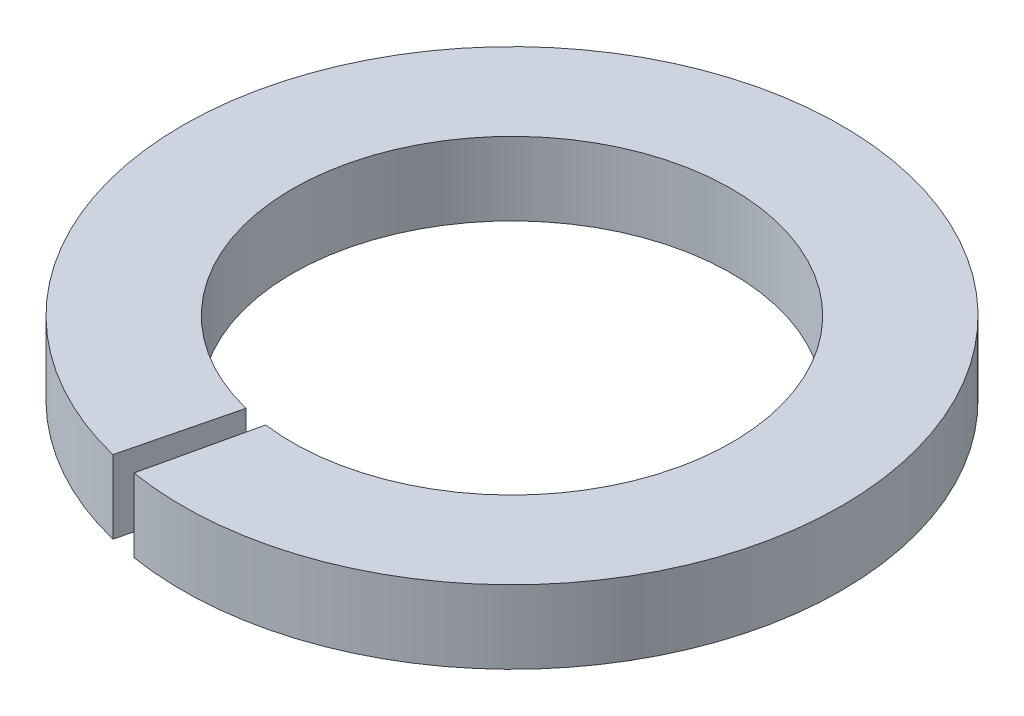
from build123d import *

# Parameters (mm, degrees)
EXTRUDE_1_DEPTH = 1


with BuildPart() as part:
    # Эскиз1 → Бобышка-Вытянуть1 (new body)
    with BuildSketch(Plane(origin=(0, 0, 0), x_dir=(1, 0, 0), z_dir=(0, 1, 0))):
        with BuildLine():
            Line((-0.721467808, -2.911955392), (-1.082201712, -4.367933087))
            ThreePointArc((-1.082201712, -4.367933087), (0.902590486, 4.408551963), (-0.721467808, -4.441788401))
            Line((-0.721467808, -4.441788401), (-0.389692262, -2.974582314))
            ThreePointArc((-0.389692262, -2.974582314), (0.556461776, 2.947940008), (-0.721467808, -2.911955392))
        make_face()
    extrude(amount=EXTRUDE_1_DEPTH)


solid = part.part
